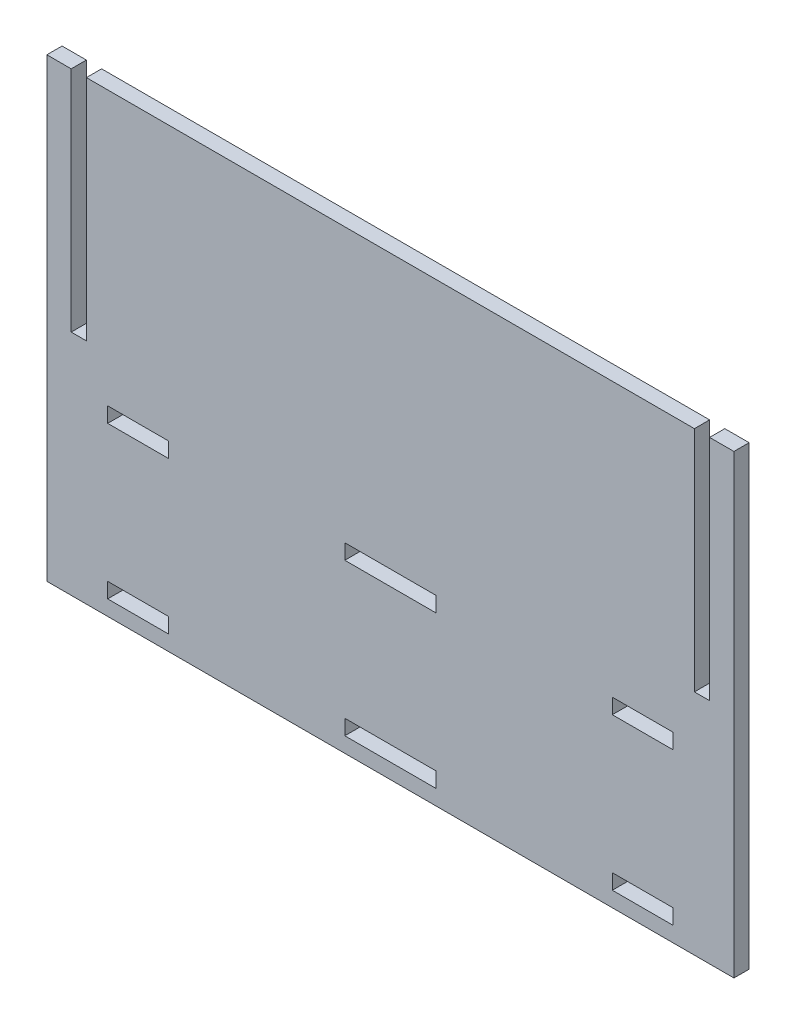
from build123d import *

# Parameters (mm, degrees)
ESQUISSE1_W        = 20
ESQUISSE1_H        = 5
BOSS_EXTRU_1_DEPTH = 5


with BuildPart() as part:
    # Esquisse1 → Boss.-Extru.1 (new body)
    with BuildSketch(Plane.XY):
        Polygon((-100, 150), (100, 150), (100, 75), (105, 75), (105, 150), (113, 150), (113, 0), (-113, 0), (-113, 150), (-105, 150), (-105, 75), (-100, 75), align=None)
        with Locations((83, 7.5)):
            Rectangle(ESQUISSE1_W, ESQUISSE1_H, mode=Mode.SUBTRACT)
        with Locations((83, 57.5)):
            Rectangle(ESQUISSE1_W, ESQUISSE1_H, mode=Mode.SUBTRACT)
        Polygon((-15, 5), (15, 5), (15, 10), (0, 10), (-15, 10), align=None, mode=Mode.SUBTRACT)
        Polygon((-15, 60), (0, 60), (15, 60), (15, 55), (-15, 55), align=None, mode=Mode.SUBTRACT)
        with Locations((-83, 7.5)):
            Rectangle(ESQUISSE1_W, ESQUISSE1_H, mode=Mode.SUBTRACT)
        with Locations((-83, 57.5)):
            Rectangle(ESQUISSE1_W, ESQUISSE1_H, mode=Mode.SUBTRACT)
    extrude(amount=BOSS_EXTRU_1_DEPTH)


solid = part.part
